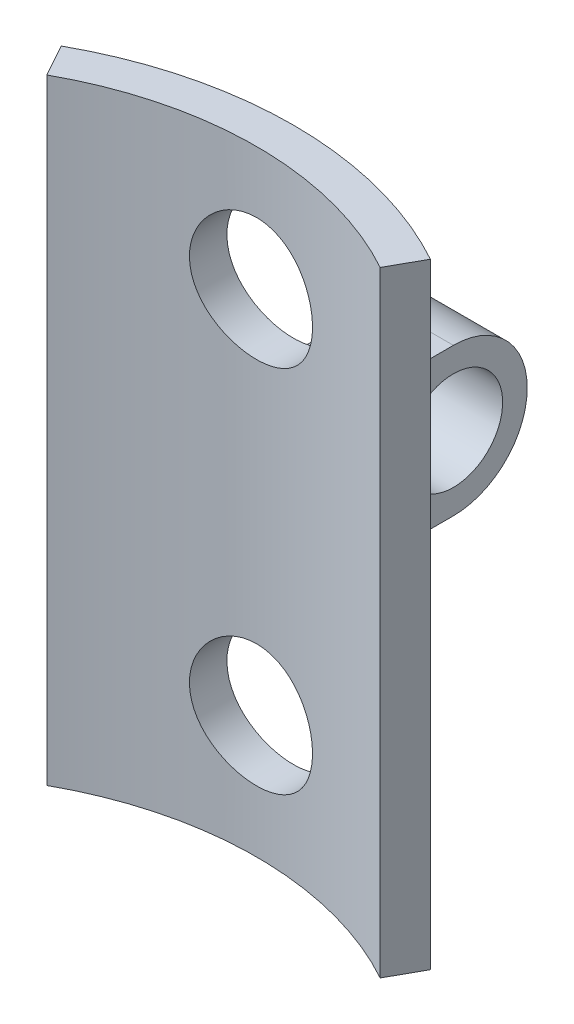
from build123d import *

# Parameters (mm, degrees)
SKETCH2_R                = 15.5
SKETCH2_R_2              = 14
BOSS_EXTRUDE1_DEPTH      = 25
SKETCH3_OUTSIDE_W        = 43.094
SKETCH3_OUTSIDE_H        = 43.094
CUT_EXTRUDE1_DEPTH       = 34.249060137
SKETCH5_R                = 2.5
CUT_EXTRUDE2_DEPTH       = 31.356218473
BOSS_EXTRUDE2_DEPTH      = 1.5
BOSS_EXTRUDE2_DEPTH_BACK = 1.5
SKETCH6_R                = 2
FILLET1_R                = 1


with BuildPart() as part:
    # Sketch2 → Boss-Extrude1 (new body)
    with BuildSketch(Plane(origin=(0, 0, 0), x_dir=(1, 0, 0), z_dir=(0, 1, 0))):
        Circle(SKETCH2_R)
        Circle(SKETCH2_R_2, mode=Mode.SUBTRACT)
    extrude(amount=BOSS_EXTRUDE1_DEPTH)

    # Sketch3 outside → Cut-Extrude1 (cut, through all)
    with BuildSketch(Plane(origin=(0, 25, 0), x_dir=(1, 0, 0), z_dir=(0, 1, 0))):
        Rectangle(SKETCH3_OUTSIDE_W, SKETCH3_OUTSIDE_H)
        with BuildLine():
            Line((0, 0), (7.5, 13.564659966))
            ThreePointArc((7.5, 13.564659966), (0, 15.5), (-7.5, 13.564659966))
            Line((-7.5, 13.564659966), (0, 0))
        make_face(mode=Mode.SUBTRACT)
    extrude(amount=-CUT_EXTRUDE1_DEPTH, mode=Mode.SUBTRACT)

    # Sketch5 → Cut-Extrude2 (cut, through all)
    with BuildSketch(Plane.XY):
        with Locations((0, 20)):
            Circle(SKETCH5_R)
        with Locations((0, 5)):
            Circle(SKETCH5_R)
    extrude(amount=-CUT_EXTRUDE2_DEPTH, mode=Mode.SUBTRACT)

    # Sketch6 → Boss-Extrude2 (add, two sides: drawn at the far end of the back side and taken through both)
    with BuildSketch(Plane(origin=(0, 7.5, 0), x_dir=(0, 1, 0), z_dir=(-1, 0, 0)).offset(-BOSS_EXTRUDE2_DEPTH_BACK)):
        with BuildLine():
            Line((2, 20.5), (2, 15.25))
            Line((2, 15.25), (8, 15.25))
            Line((8, 15.25), (8, 20.5))
            ThreePointArc((8, 20.5), (5, 23.5), (2, 20.5))
        make_face()
        with Locations((5, 20.5)):
            Circle(SKETCH6_R, mode=Mode.SUBTRACT)
    extrude(amount=BOSS_EXTRUDE2_DEPTH + BOSS_EXTRUDE2_DEPTH_BACK)

    # Fillet1
    fillet1_edges = [part.edges().sort_by_distance(p)[0] for p in [
        (1.5, 12.5, -15.427248621),
        (-1.5, 12.5, -15.427248621),
    ]]
    fillet(fillet1_edges, radius=FILLET1_R)


solid = part.part
